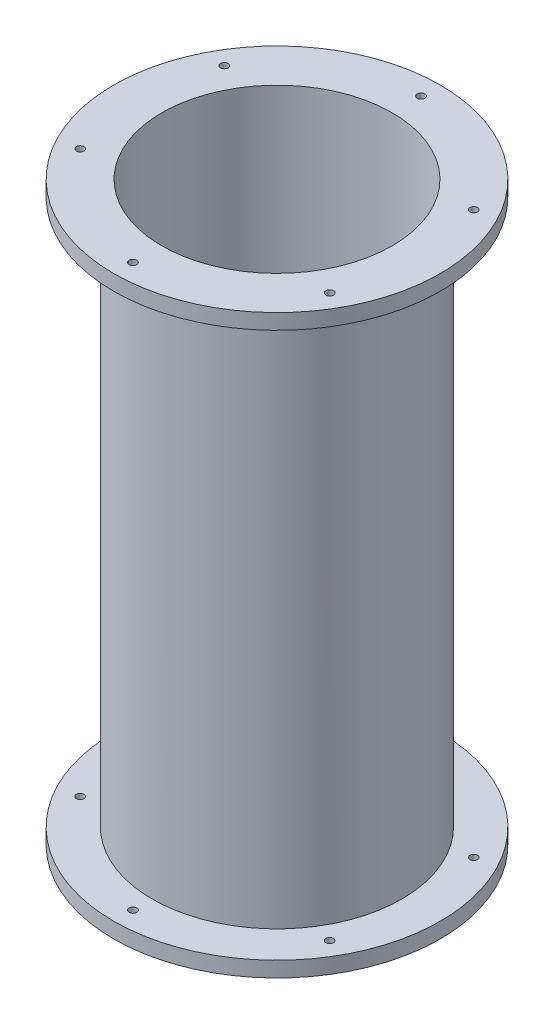
from build123d import *

# Parameters (mm, degrees)
SKETCH_1_R               = 65
SKETCH_1_R_2             = 60
EXTRUDE_1_DEPTH          = 300
SKETCH_2_R               = 85
SKETCH_2_R_2             = 65
EXTRUDE_1_2_DEPTH        = 8
SKETCH_3_R               = 2
CUT_EXTRUDE_1_DEPTH      = 301
SKETCH_4_R               = 85
SKETCH_4_R_2             = 65
EXTRUDE_2_DEPTH          = 8
SKETCH_5_R               = 2
CUT_EXTRUDE_2_DEPTH      = 1
CUT_EXTRUDE_2_DEPTH_BACK = 301


with BuildPart() as part:
    # 草图1 → Extrude 1 (new body)
    with BuildSketch(Plane(origin=(0, 0, 0), x_dir=(1, 0, 0), z_dir=(0, 1, 0))):
        Circle(SKETCH_1_R)
        Circle(SKETCH_1_R_2, mode=Mode.SUBTRACT)
    extrude(amount=EXTRUDE_1_DEPTH)

    # 草图2 → Extrude 1 2 (add)
    with BuildSketch(Plane(origin=(0, 300, 0), x_dir=(1, 0, 0), z_dir=(0, 1, 0))):
        Circle(SKETCH_2_R)
        Circle(SKETCH_2_R_2, mode=Mode.SUBTRACT)
    extrude(amount=-EXTRUDE_1_2_DEPTH)

    # 草图3 → 切除-拉伸1 (cut, through all)
    with BuildSketch(Plane(origin=(0, 300, 0), x_dir=(1, 0, 0), z_dir=(0, 1, 0))):
        with Locations((0, 75)):
            Circle(SKETCH_3_R)
        with Locations((64.951905284, 37.5)):
            Circle(SKETCH_3_R)
        with Locations((64.951905284, -37.5)):
            Circle(SKETCH_3_R)
        with Locations((0, -75)):
            Circle(SKETCH_3_R)
        with Locations((-64.951905284, -37.5)):
            Circle(SKETCH_3_R)
        with Locations((-64.951905284, 37.5)):
            Circle(SKETCH_3_R)
    extrude(amount=-CUT_EXTRUDE_1_DEPTH, mode=Mode.SUBTRACT)

    # 草图4 → 凸台-拉伸2 (add)
    with BuildSketch(Plane.XZ):
        Circle(SKETCH_4_R)
        Circle(SKETCH_4_R_2, mode=Mode.SUBTRACT)
    extrude(amount=-EXTRUDE_2_DEPTH)

    # 草图5 → 切除-拉伸2 (cut, two sides)
    with BuildSketch(Plane.XZ) as cut_extrude_2_sk:
        with Locations((0, 75)):
            Circle(SKETCH_5_R)
        with Locations((64.951905284, 37.5)):
            Circle(SKETCH_5_R)
        with Locations((64.951905284, -37.5)):
            Circle(SKETCH_5_R)
        with Locations((0, -75)):
            Circle(SKETCH_5_R)
        with Locations((-64.951905284, -37.5)):
            Circle(SKETCH_5_R)
        with Locations((-64.951905284, 37.5)):
            Circle(SKETCH_5_R)
    extrude(amount=CUT_EXTRUDE_2_DEPTH, mode=Mode.SUBTRACT)
    extrude(cut_extrude_2_sk.sketch, amount=-CUT_EXTRUDE_2_DEPTH_BACK, mode=Mode.SUBTRACT)


solid = part.part
